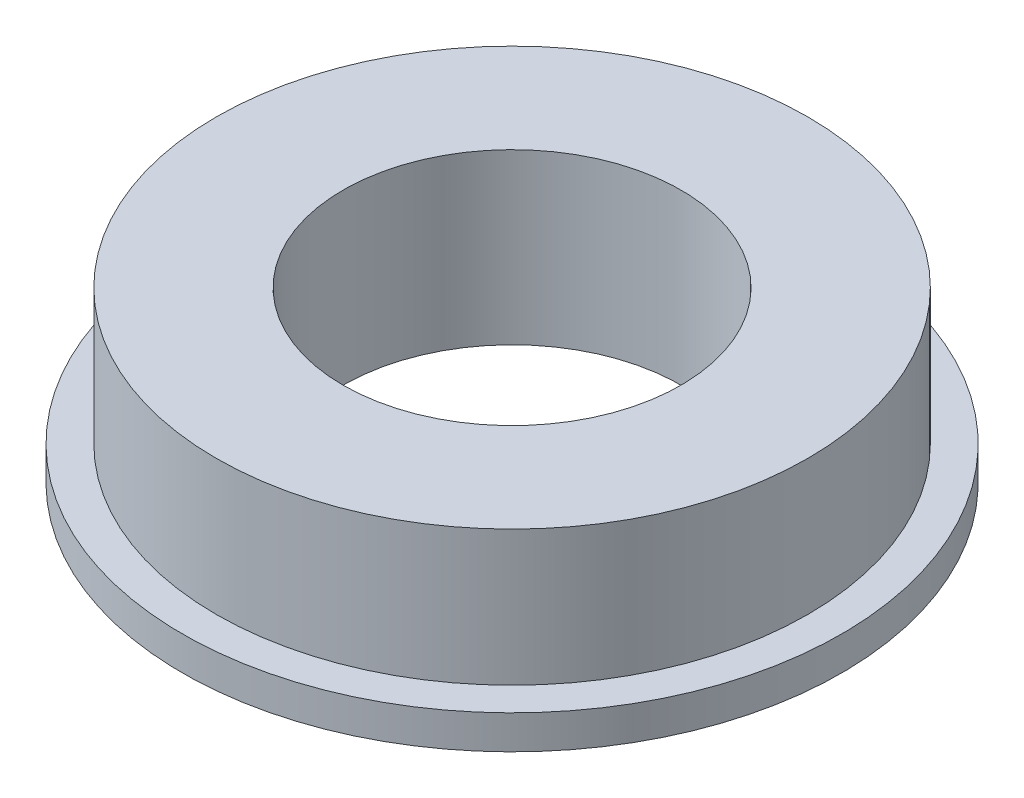
from build123d import *

# Parameters (mm, degrees)
SKETCH_1_R      = 7
SKETCH_1_R_2    = 4
EXTRUDE_1_DEPTH = 4
SKETCH_2_R      = 7.8
SKETCH_2_R_2    = 4
EXTRUDE_2_DEPTH = 0.8


with BuildPart() as part:
    # 草图1 → 凸台-拉伸1 (new body)
    with BuildSketch(Plane(origin=(0, 0, 0), x_dir=(1, 0, 0), z_dir=(0, 1, 0))):
        Circle(SKETCH_1_R)
        Circle(SKETCH_1_R_2, mode=Mode.SUBTRACT)
    extrude(amount=EXTRUDE_1_DEPTH)

    # 草图2 → 凸台-拉伸2 (add)
    with BuildSketch(Plane.XZ):
        Circle(SKETCH_2_R)
        Circle(SKETCH_2_R_2, mode=Mode.SUBTRACT)
    extrude(amount=-EXTRUDE_2_DEPTH)


solid = part.part
